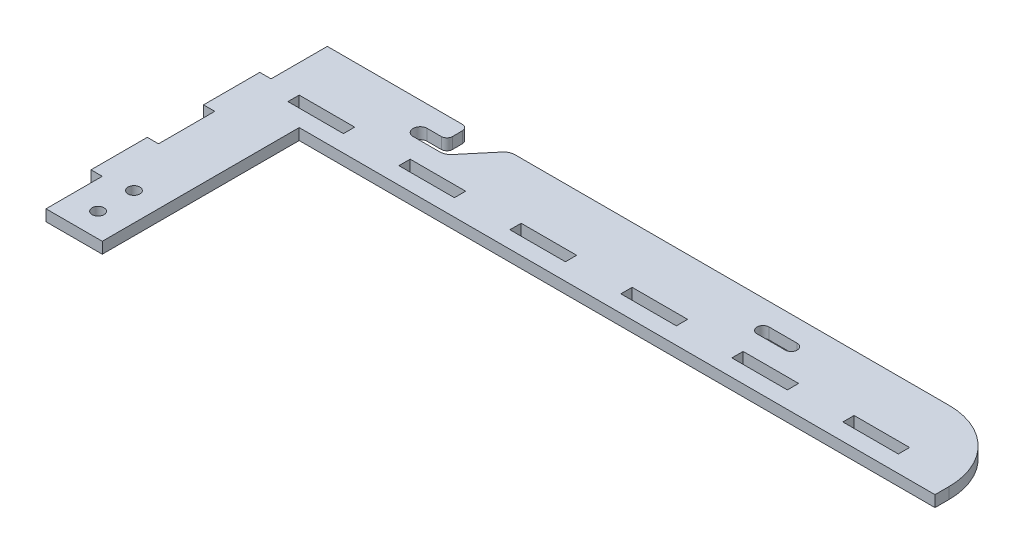
from build123d import *

# Parameters (mm, degrees)
SKETCH1_R           = 2.125
SKETCH1_W           = 19.725
SKETCH1_H           = 4
BOSS_EXTRUDE1_DEPTH = 4


with BuildPart() as part:
    # Sketch1 → Boss-Extrude1 (new body)
    with BuildSketch(Plane(origin=(0, 0, 0), x_dir=(1, 0, 0), z_dir=(0, 1, 0))):
        with BuildLine():
            Line((4, 0), (4, 20))
            Line((4, 20), (0, 20))
            Line((0, 20), (0, 40))
            Line((0, 40), (4, 40))
            Line((4, 40), (4, 60))
            Line((4, 60), (0, 60))
            Line((0, 60), (0, 80))
            Line((0, 80), (4, 80))
            Line((4, 80), (4, 100))
            Line((4, 100), (52, 100))
            ThreePointArc((52, 100), (53.414213562, 99.414213562), (54, 98))
            Line((54, 98), (54, 94.5))
            ThreePointArc((54, 94.5), (53.414213562, 93.085786438), (52, 92.5))
            Line((52, 92.5), (47, 92.5))
            ThreePointArc((47, 92.5), (44.5, 90), (47, 87.5))
            Line((47, 87.5), (56.460109826, 87.5))
            ThreePointArc((56.460109826, 87.5), (58.150582873, 87.874768852), (59.524287598, 88.928849561))
            Line((59.524287598, 88.928849561), (67.615138708, 98.571150439))
            ThreePointArc((67.615138708, 98.571150439), (68.988843434, 99.625231148), (70.679316481, 100))
            Line((70.679316481, 100), (225, 100))
            ThreePointArc((225, 100), (242.67766953, 92.67766953), (250, 75))
            Line((250, 75), (250, 70))
            Line((250, 70), (24, 70))
            Line((24, 70), (24, 0))
            Line((24, 0), (4, 0))
        make_face()
        with Locations((14, 8.5)):
            Circle(SKETCH1_R, mode=Mode.SUBTRACT)
        with Locations((14, 21.25)):
            Circle(SKETCH1_R, mode=Mode.SUBTRACT)
        with Locations((63.3125, 78)):
            Rectangle(SKETCH1_W, SKETCH1_H, mode=Mode.SUBTRACT)
        with Locations((23.8625, 78)):
            Rectangle(SKETCH1_W, SKETCH1_H, mode=Mode.SUBTRACT)
        with Locations((102.7625, 78)):
            Rectangle(SKETCH1_W, SKETCH1_H, mode=Mode.SUBTRACT)
        with Locations((142.2125, 78)):
            Rectangle(SKETCH1_W, SKETCH1_H, mode=Mode.SUBTRACT)
        with Locations((181.6625, 78)):
            Rectangle(SKETCH1_W, SKETCH1_H, mode=Mode.SUBTRACT)
        with Locations((221.1125, 78)):
            Rectangle(SKETCH1_W, SKETCH1_H, mode=Mode.SUBTRACT)
        with BuildLine():
            Line((168.885, 92.125), (178.885, 92.125))
            ThreePointArc((178.885, 92.125), (181.01, 90), (178.885, 87.875))
            Line((178.885, 87.875), (168.885, 87.875))
            ThreePointArc((168.885, 87.875), (166.76, 90), (168.885, 92.125))
        make_face(mode=Mode.SUBTRACT)
    extrude(amount=BOSS_EXTRUDE1_DEPTH)


solid = part.part
